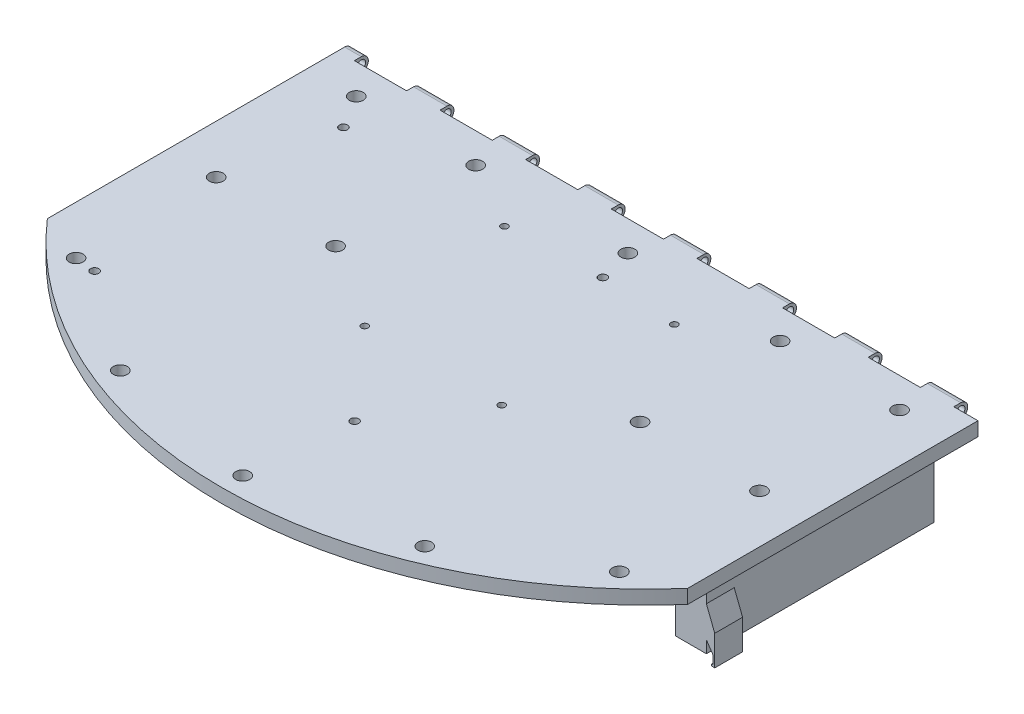
from build123d import *

# Parameters (mm, degrees)
BOSS_EXTRUDE1_DEPTH      = 5.08
SKETCH2_W                = 11.329576632
SKETCH2_H                = 83
BOSS_EXTRUDE2_DEPTH      = 23.622
BOSS_EXTRUDE3_DEPTH      = 154.884757
BOSS_EXTRUDE3_DEPTH_BACK = 154.884757
SKETCH4_W                = 19.05
SKETCH4_H                = 5.08
CUT_EXTRUDE2_DEPTH       = 5.08
SKETCH5_R                = 1.25
CUT_EXTRUDE3_DEPTH       = 5.08
SKETCH6_W                = 87.378176536
SKETCH6_H                = 116.226136144
CUT_EXTRUDE5_DEPTH       = 5.08
SKETCH7_R                = 2.54
CUT_EXTRUDE6_DEPTH       = 5.08
SKETCH8_R                = 1.55
CUT_EXTRUDE7_DEPTH       = 224.79
BOSS_EXTRUDE4_DEPTH      = 10.16
BOSS_EXTRUDE5_DEPTH      = 10.16
SKETCH12_R               = 1.5
CUT_EXTRUDE8_DEPTH       = 5.08


with BuildPart() as part:
    # Sketch1 → Boss-Extrude1 (new body)
    with BuildSketch(Plane(origin=(0, 0, 0), x_dir=(1, 0, 0), z_dir=(0, 1, 0))):
        with BuildLine():
            ThreePointArc((154.94, 0), (154.926188711, 2.068731835), (154.884757307, 4.137094858))
            Line((154.884757307, 4.137094858), (-154.884757307, 4.137094858))
            ThreePointArc((-154.884757307, 4.137094858), (-2.068731835, -154.926188711), (154.94, 0))
        make_face()
    extrude(amount=BOSS_EXTRUDE1_DEPTH)

    # Sketch2 → Boss-Extrude2 (add)
    with BuildSketch(Plane(origin=(0, 0, 0), x_dir=(-1, 0, 0), z_dir=(0, -1, 0))):
        with Locations((-106.53347234, -48.850905142)):
            Rectangle(SKETCH2_W, SKETCH2_H)
        with Locations((106.53347234, -48.850905142)):
            Rectangle(SKETCH2_W, SKETCH2_H)
    extrude(amount=BOSS_EXTRUDE2_DEPTH)

    # Sketch3 → Boss-Extrude3 (add, two sides)
    with BuildSketch(Plane(origin=(0, 0, 0), x_dir=(0, 0, -1), z_dir=(1, 0, 0))) as boss_extrude3_sk:
        with BuildLine():
            ThreePointArc((9.217094858, 2.54), (8.473146082, 4.336051224), (6.677094858, 5.08))
            Line((6.677094858, 5.08), (6.677094858, 0))
            ThreePointArc((6.677094858, 0), (8.473146082, 0.743948776), (9.217094858, 2.54))
        make_face()
        with BuildLine():
            Line((6.677094858, 0), (6.677094858, 5.08))
            ThreePointArc((6.677094858, 5.08), (4.881043633, 4.336051224), (4.137094858, 2.54))
            ThreePointArc((4.137094858, 2.54), (4.881043633, 0.743948776), (6.677094858, 0))
        make_face()
        with BuildLine():
            Line((6.677094858, 5.08), (4.137094858, 5.08))
            Line((4.137094858, 5.08), (4.137094858, 2.54))
            ThreePointArc((4.137094858, 2.54), (4.881043633, 4.336051224), (6.677094858, 5.08))
        make_face()
        with BuildLine():
            ThreePointArc((6.677094858, 0), (4.881043633, 0.743948776), (4.137094858, 2.54))
            Line((4.137094858, 2.54), (4.137094858, 0))
            Line((4.137094858, 0), (6.677094858, 0))
        make_face()
    extrude(amount=BOSS_EXTRUDE3_DEPTH)
    extrude(boss_extrude3_sk.sketch, amount=-BOSS_EXTRUDE3_DEPTH_BACK)

    # Sketch4 → Cut-Extrude2 (cut)
    with BuildSketch(Plane(origin=(0, 5.08, 0), x_dir=(1, 0, 0), z_dir=(0, 1, 0))):
        with Locations((-132.429084549, 6.677094858)):
            Rectangle(SKETCH4_W, SKETCH4_H)
        with Locations((-101.187084549, 6.677094858)):
            Rectangle(SKETCH4_W, SKETCH4_H)
        with Locations((-69.945084549, 6.677094858)):
            Rectangle(SKETCH4_W, SKETCH4_H)
        with Locations((-38.703084549, 6.677094858)):
            Rectangle(SKETCH4_W, SKETCH4_H)
        with Locations((-7.461084549, 6.677094858)):
            Rectangle(SKETCH4_W, SKETCH4_H)
        with Locations((23.780915451, 6.677094858)):
            Rectangle(SKETCH4_W, SKETCH4_H)
        with Locations((55.022915451, 6.677094858)):
            Rectangle(SKETCH4_W, SKETCH4_H)
        with Locations((86.264915451, 6.677094858)):
            Rectangle(SKETCH4_W, SKETCH4_H)
        with Locations((117.506915451, 6.677094858)):
            Rectangle(SKETCH4_W, SKETCH4_H)
        with Locations((148.748915451, 6.677094858)):
            Rectangle(SKETCH4_W, SKETCH4_H)
    extrude(amount=-CUT_EXTRUDE2_DEPTH, mode=Mode.SUBTRACT)

    # Sketch5 → Cut-Extrude3 (cut)
    with BuildSketch(Plane(origin=(0, 5.08, 0), x_dir=(1, 0, 0), z_dir=(0, 1, 0))):
        with Locations((-31, -20.830897674)):
            Circle(SKETCH5_R)
        with Locations((-25, -77.830897674)):
            Circle(SKETCH5_R)
        with Locations((31, -20.830897674)):
            Circle(SKETCH5_R)
        with Locations((25, -77.830897674)):
            Circle(SKETCH5_R)
    extrude(amount=-CUT_EXTRUDE3_DEPTH, mode=Mode.SUBTRACT)

    # Sketch6 → Cut-Extrude5 (cut)
    with BuildSketch(Plane(origin=(0, 5.08, 0), x_dir=(1, 0, 0), z_dir=(0, 1, 0))):
        with Locations((160.497172817, -43.682192054)):
            Rectangle(SKETCH6_W, SKETCH6_H)
        with Locations((-160.497172817, -43.682192054)):
            Rectangle(SKETCH6_W, SKETCH6_H)
    extrude(amount=-CUT_EXTRUDE5_DEPTH, mode=Mode.SUBTRACT)

    # Sketch7 → Cut-Extrude6 (cut)
    with BuildSketch(Plane(origin=(0, 5.08, 0), x_dir=(1, 0, 0), z_dir=(0, 1, 0))):
        with Locations((0, -147.32)):
            Circle(SKETCH7_R)
        with Locations((0, -6.788708839)):
            Circle(SKETCH7_R)
        with Locations((55.543786685, -136.448049311)):
            Circle(SKETCH7_R)
        with Locations((-55.543786685, -136.448049311)):
            Circle(SKETCH7_R)
        with Locations((-99.114141025, -108.993437642)):
            Circle(SKETCH7_R)
        with Locations((-99.114141025, -6.788708839)):
            Circle(SKETCH7_R)
        with Locations((99.114141025, -6.788708839)):
            Circle(SKETCH7_R)
        with Locations((-55.543786685, -6.788708839)):
            Circle(SKETCH7_R)
        with Locations((55.543786685, -6.788708839)):
            Circle(SKETCH7_R)
        with Locations((99.114141025, -108.993437642)):
            Circle(SKETCH7_R)
        with Locations((-99.114141025, -57.89107324)):
            Circle(SKETCH7_R)
        with Locations((99.114141025, -57.89107324)):
            Circle(SKETCH7_R)
        with Locations((55.543786685, -57.89107324)):
            Circle(SKETCH7_R)
        with Locations((-55.543786685, -57.89107324)):
            Circle(SKETCH7_R)
    extrude(amount=-CUT_EXTRUDE6_DEPTH, mode=Mode.SUBTRACT)

    # Sketch8 → Cut-Extrude7 (cut)
    with BuildSketch(Plane(origin=(107.981915451, 0, 0), x_dir=(0, 0, -1), z_dir=(1, 0, 0))):
        with Locations((6.677094858, 2.54)):
            Circle(SKETCH8_R)
    extrude(amount=-CUT_EXTRUDE7_DEPTH, mode=Mode.SUBTRACT)

    # Sketch9 → Boss-Extrude4 (add)
    with BuildSketch(Plane.XY.offset(90.350905142)):
        Polygon((115.246260656, -15.633482352), (112.198260656, -15.633482352), (112.198260656, -19.189482352), (114.611260656, -22.745482352), (114.611260656, -25.77835243), (114.103260656, -25.886331163), (114.103260656, -26.46263354), (114.611260656, -26.570612273), (115.246260656, -26.570612273), align=None)
        Polygon((-114.611260656, -25.77835243), (-114.611260656, -22.745482352), (-112.198260656, -19.189482352), (-112.198260656, -15.633482352), (-115.246260656, -15.633482352), (-115.246260656, -26.570612273), (-114.611260656, -26.570612273), (-114.103260656, -26.46263354), (-114.103260656, -25.886331163), align=None)
    extrude(amount=-BOSS_EXTRUDE4_DEPTH)

    # Sketch11 → Boss-Extrude5 (add)
    with BuildSketch(Plane.XY.offset(90.350905142)):
        Polygon((112.198260656, -7.816741176), (115.246260656, -15.633482352), (112.198260656, -15.633482352), align=None)
        Polygon((-115.246260656, -15.633482352), (-112.198260656, -15.633482352), (-112.198260656, -7.816741176), align=None)
    extrude(amount=-BOSS_EXTRUDE5_DEPTH)

    # Sketch12 → Cut-Extrude8 (cut)
    with BuildSketch(Plane(origin=(0, 5.08, 0), x_dir=(1, 0, 0), z_dir=(0, 1, 0))):
        with Locations((-91.646084549, -18.920905142)):
            Circle(SKETCH12_R)
        with Locations((-91.646084549, -109.710905142)):
            Circle(SKETCH12_R)
        with Locations((3.207915451, -109.710905142)):
            Circle(SKETCH12_R)
        with Locations((3.094524951, -19.034295642)):
            Circle(SKETCH12_R)
    extrude(amount=-CUT_EXTRUDE8_DEPTH, mode=Mode.SUBTRACT)


solid = part.part
